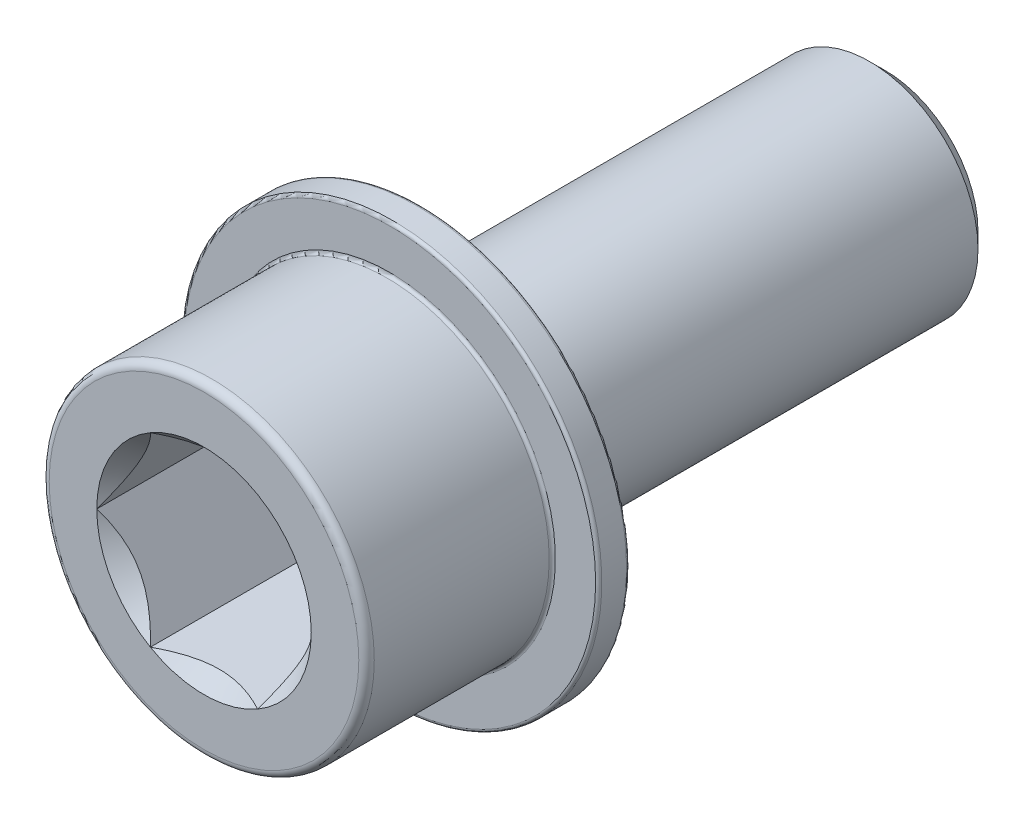
from build123d import *

# Parameters (mm, degrees)
SCHIZZO1_R                   = 7
ESTRUSIONE_ESTRUSIONE1_DEPTH = 30
SMUSSO1_SIZE                 = 1
SCHIZZO6_R                   = 10.5
ESTRUSIONE_ESTRUSIONE3_DEPTH = 14
TAGLIO_ESTRUSIONE3_DEPTH     = 10
SCHIZZO8_R                   = 6.92820323
TAGLIO_ESTRUSIONE4_DEPTH     = 1
TAGLIO_ESTRUSIONE4_TAPER     = 43
RACCORDO5_R                  = 0.5
SCHIZZO9_R                   = 13.5
SCHIZZO9_R_2                 = 10.5
ESTRUSIONE_ESTRUSIONE4_DEPTH = 2
RACCORDO6_R                  = 0.2


with BuildPart() as part:
    # Schizzo1 → Estrusione-Estrusione1 (new body)
    with BuildSketch(Plane.XY):
        Circle(SCHIZZO1_R)
    extrude(amount=ESTRUSIONE_ESTRUSIONE1_DEPTH)

    # Smusso1
    smusso1_edges = [part.edges().sort_by_distance(p)[0] for p in [
        (-7, 0, 0),
    ]]
    chamfer(smusso1_edges, length=SMUSSO1_SIZE)

    # Schizzo6 → Estrusione-Estrusione3 (add)
    with BuildSketch(Plane.XY.offset(30)):
        Circle(SCHIZZO6_R)
    extrude(amount=ESTRUSIONE_ESTRUSIONE3_DEPTH)

    # Schizzo7 → Taglio-Estrusione3 (cut)
    with BuildSketch(Plane.XY.offset(44)):
        Polygon((3.464101615, 6), (-3.464101615, 6), (-6.92820323, 0), (-3.464101615, -6), (3.464101615, -6), (6.92820323, 0), align=None)
    extrude(amount=-TAGLIO_ESTRUSIONE3_DEPTH, mode=Mode.SUBTRACT)

    # Schizzo8 → Taglio-Estrusione4 (cut)
    with BuildSketch(Plane.XY.offset(44)):
        Circle(SCHIZZO8_R)
    extrude(amount=-TAGLIO_ESTRUSIONE4_DEPTH, taper=TAGLIO_ESTRUSIONE4_TAPER, mode=Mode.SUBTRACT)

    # Raccordo5
    raccordo5_edges = [part.edges().sort_by_distance(p)[0] for p in [
        (-10.5, 0, 44),
    ]]
    fillet(raccordo5_edges, radius=RACCORDO5_R)

    # Schizzo9 → Estrusione-Estrusione4 (add)
    with BuildSketch(Plane(origin=(0, 0, 30), x_dir=(-1, 0, 0), z_dir=(0, 0, -1))):
        Circle(SCHIZZO9_R)
        Circle(SCHIZZO9_R_2, mode=Mode.SUBTRACT)
    extrude(amount=-ESTRUSIONE_ESTRUSIONE4_DEPTH)

    # Raccordo6
    raccordo6_edges = [part.edges().sort_by_distance(p)[0] for p in [
        (-10.5, 0, 32),
        (13.5, 0, 32),
        (13.5, 0, 30),
    ]]
    fillet(raccordo6_edges, radius=RACCORDO6_R)


solid = part.part
